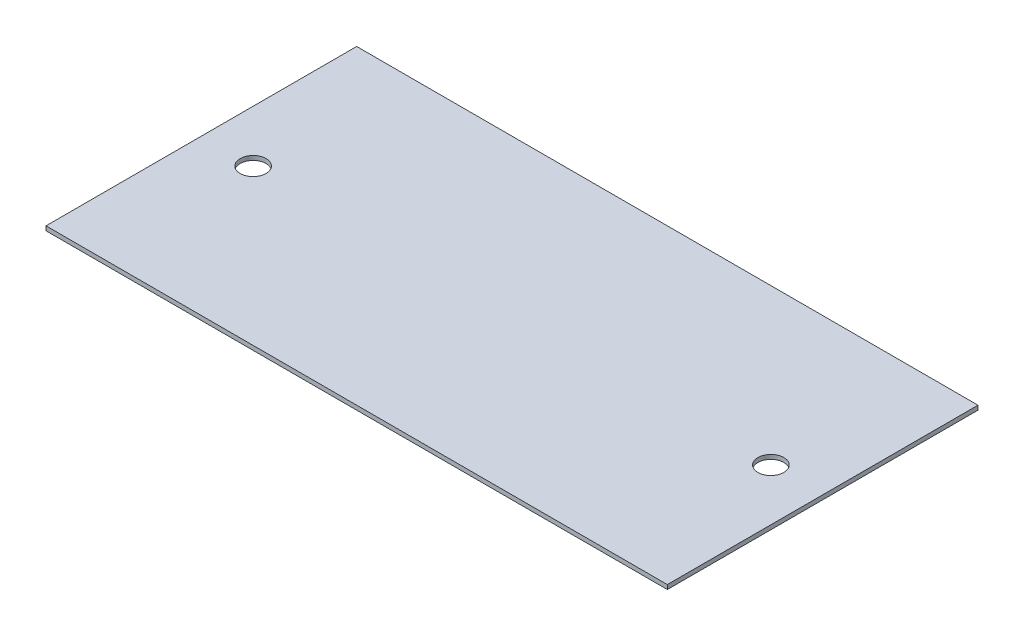
from build123d import *

# Parameters (mm, degrees)
SKETCH1_W           = 914.4
SKETCH1_H           = 457.2
BOSS_EXTRUDE1_DEPTH = 6.35
SKETCH2_R           = 19.05
CUT_EXTRUDE1_DEPTH  = 7.35


with BuildPart() as part:
    # Sketch1 → Boss-Extrude1 (new body)
    with BuildSketch(Plane(origin=(0, 0, 0), x_dir=(1, 0, 0), z_dir=(0, 1, 0))):
        with Locations((457.2, 228.6)):
            Rectangle(SKETCH1_W, SKETCH1_H)
    extrude(amount=BOSS_EXTRUDE1_DEPTH)

    # Sketch2 → Cut-Extrude1 (cut, through all)
    with BuildSketch(Plane(origin=(0, 6.35, 0), x_dir=(1, 0, 0), z_dir=(0, 1, 0))):
        with Locations((76.2, 228.6)):
            Circle(SKETCH2_R)
        with Locations((838.2, 228.6)):
            Circle(SKETCH2_R)
    extrude(amount=-CUT_EXTRUDE1_DEPTH, mode=Mode.SUBTRACT)


solid = part.part
